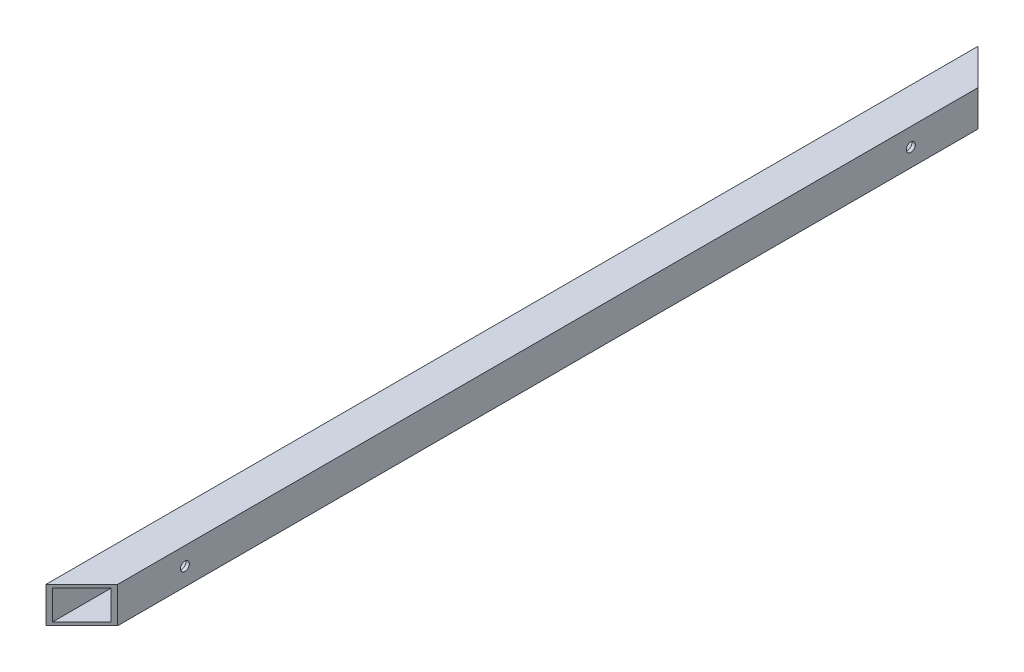
from build123d import *

# Parameters (mm, degrees)
SKETCH1_W           = 50.8
SKETCH1_H           = 50.8
SKETCH1_W_2         = 41.275
SKETCH1_H_2         = 41.275
EXTRUDE_THIN1_DEPTH = 660.4
CUT_EXTRUDE1_DEPTH  = 51.8
SKETCH4_R           = 6.35
CUT_EXTRUDE2_DEPTH  = 51.8


with BuildPart() as part:
    # Sketch1 → Extrude-Thin1 (new body, symmetric)
    with BuildSketch(Plane.XY):
        with Locations((-254, 958.85)):
            Rectangle(SKETCH1_W, SKETCH1_H)
        with Locations((-254, 958.85)):
            Rectangle(SKETCH1_W_2, SKETCH1_H_2, mode=Mode.SUBTRACT)
    extrude(amount=EXTRUDE_THIN1_DEPTH, both=True)

    # Sketch3 → Cut-Extrude1 (cut, through all)
    with BuildSketch(Plane.XZ.offset(-933.45)):
        Polygon((-279.4, 660.4), (-228.6, 609.6), (-228.6, 660.4), align=None)
        Polygon((-279.4, -660.4), (-228.6, -609.6), (-228.6, -660.4), align=None)
    extrude(amount=-CUT_EXTRUDE1_DEPTH, mode=Mode.SUBTRACT)

    # Sketch4 → Cut-Extrude2 (cut, through all)
    with BuildSketch(Plane.ZY.offset(279.4)):
        with Locations((514.35, 958.85)):
            Circle(SKETCH4_R)
        with Locations((-514.35, 958.85)):
            Circle(SKETCH4_R)
    extrude(amount=-CUT_EXTRUDE2_DEPTH, mode=Mode.SUBTRACT)


solid = part.part
